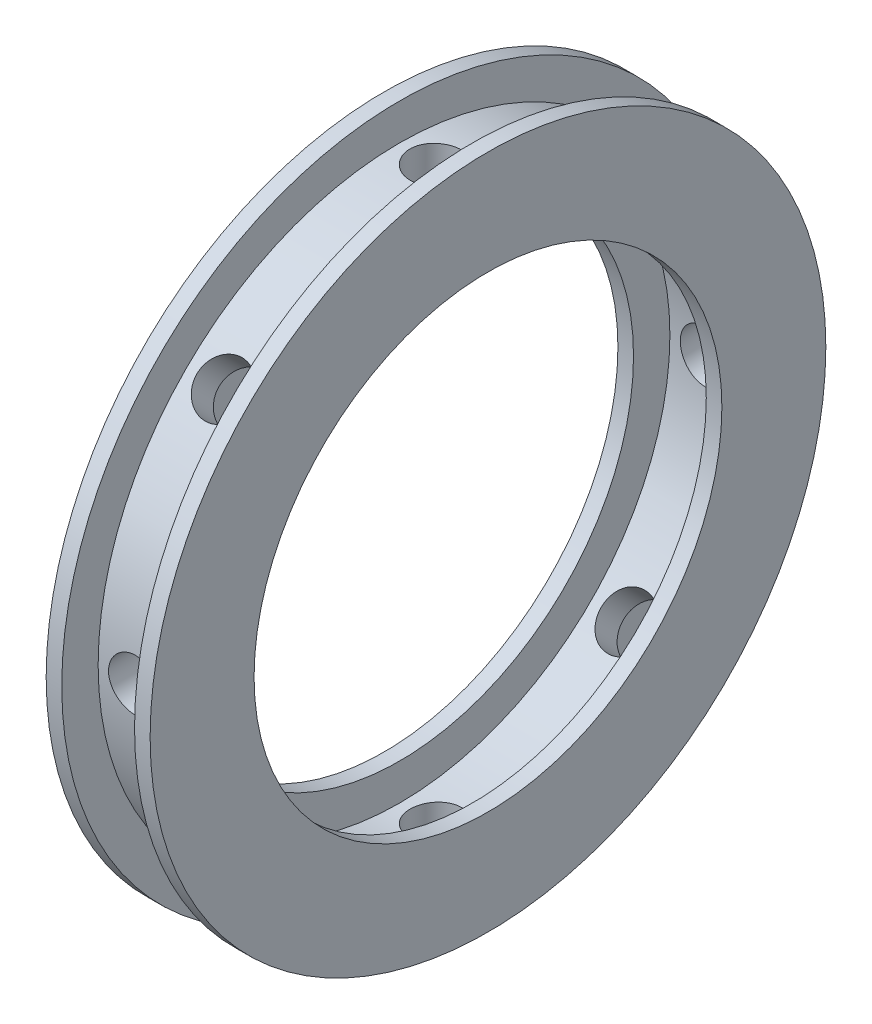
from build123d import *

# Parameters (mm, degrees)
SKETCH2_R          = 2.5
CUT_EXTRUDE1_DEPTH = 33.5
CIRPATTERN1_COUNT  = 8


with BuildPart() as part:
    # Sketch1 → Revolve1 (revolve)
    with BuildSketch(Plane.XY):
        Polygon((-3.5, 29), (3.5, 29), (3.5, 32.5), (5, 32.5), (5, 22.5), (3.5, 22.5), (3.5, 26), (-3.5, 26), (-3.5, 22.5), (-5, 22.5), (-5, 32.5), (-3.5, 32.5), align=None)
    revolve(axis=Axis((-5.608551002, 0, 0), (1, 0, 0)))

    # Sketch2 → Cut-Extrude1 (cut, through all)
    with BuildSketch(Plane(origin=(0, 0, 0), x_dir=(1, 0, 0), z_dir=(0, 1, 0))):
        Circle(SKETCH2_R)
    cut_extrude1 = extrude(amount=CUT_EXTRUDE1_DEPTH, mode=Mode.SUBTRACT)

    # CirPattern1: Cut-Extrude1 ×8 about axis
    cirpattern1_axis = Axis((-5.608551002, 0, 0), (-1, 0, 0))
    for i in range(1, CIRPATTERN1_COUNT):
        add(cut_extrude1.rotate(cirpattern1_axis, i * 360 / CIRPATTERN1_COUNT), mode=Mode.SUBTRACT)


solid = part.part
